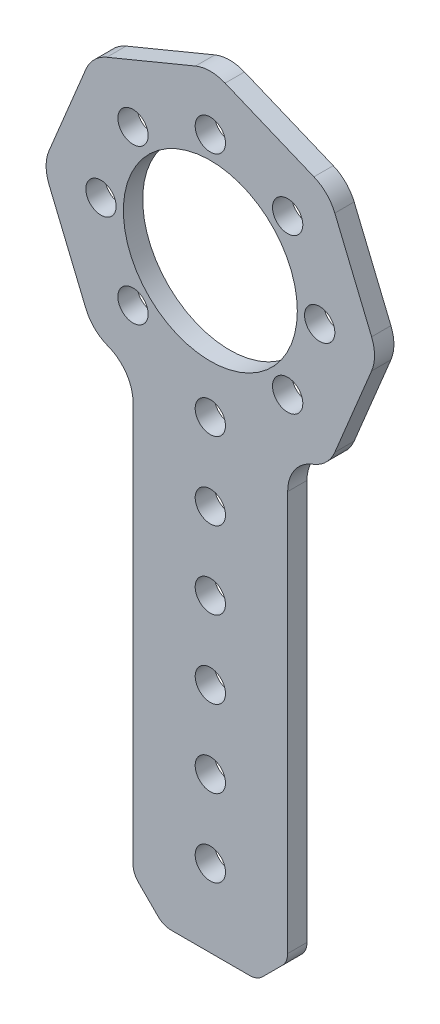
from build123d import *

# Parameters (mm, degrees)
SKETCH1_R           = 2.4892
SKETCH1_R_2         = 14.2875
BOSS_EXTRUDE1_DEPTH = 3.175


with BuildPart() as part:
    # Sketch1 → Boss-Extrude1 (new body)
    with BuildSketch(Plane(origin=(0, 0, -3.175), x_dir=(-1, 0, 0), z_dir=(0, 0, -1))):
        with BuildLine():
            Line((8.578679656, -97.553569989), (11.821320344, -94.310929302))
            ThreePointArc((11.821320344, -94.310929302), (12.471638598, -93.337659255), (12.7, -92.189608958))
            Line((12.7, -92.189608958), (12.7, -26.475183996))
            ThreePointArc((12.7, -26.475183996), (13.770167962, -22.947313016), (16.619960204, -20.608548965))
            Line((16.619960204, -20.608548965), (17.010278569, -20.446873805))
            ThreePointArc((17.010278569, -20.446873805), (19.070366834, -19.070366834), (20.446873805, -17.010278569))
            Line((20.446873805, -17.010278569), (26.486206447, -2.430039796))
            ThreePointArc((26.486206447, -2.430039796), (26.969571416, 0), (26.486206447, 2.430039796))
            Line((26.486206447, 2.430039796), (20.446873805, 17.010278569))
            ThreePointArc((20.446873805, 17.010278569), (19.070366834, 19.070366834), (17.010278569, 20.446873805))
            Line((17.010278569, 20.446873805), (2.430039796, 26.486206447))
            ThreePointArc((2.430039796, 26.486206447), (0, 26.969571416), (-2.430039796, 26.486206447))
            Line((-2.430039796, 26.486206447), (-17.010278569, 20.446873805))
            ThreePointArc((-17.010278569, 20.446873805), (-19.070366834, 19.070366834), (-20.446873805, 17.010278569))
            Line((-20.446873805, 17.010278569), (-26.486206447, 2.430039796))
            ThreePointArc((-26.486206447, 2.430039796), (-26.969571416, 0), (-26.486206447, -2.430039796))
            Line((-26.486206447, -2.430039796), (-20.446873805, -17.010278569))
            ThreePointArc((-20.446873805, -17.010278569), (-19.070366834, -19.070366834), (-17.010278569, -20.446873805))
            Line((-17.010278569, -20.446873805), (-16.619960204, -20.608548965))
            ThreePointArc((-16.619960204, -20.608548965), (-13.770167962, -22.947313016), (-12.7, -26.475183996))
            Line((-12.7, -26.475183996), (-12.7, -92.189608958))
            ThreePointArc((-12.7, -92.189608958), (-12.471638598, -93.337659255), (-11.821320344, -94.310929302))
            Line((-11.821320344, -94.310929302), (-8.578679656, -97.553569989))
            ThreePointArc((-8.578679656, -97.553569989), (-7.60540961, -98.203888243), (-6.457359313, -98.432249645))
            Line((-6.457359313, -98.432249645), (6.457359313, -98.432249645))
            ThreePointArc((6.457359313, -98.432249645), (7.60540961, -98.203888243), (8.578679656, -97.553569989))
        make_face()
        with Locations((12.7, -12.7)):
            Circle(SKETCH1_R, mode=Mode.SUBTRACT)
        Circle(SKETCH1_R_2, mode=Mode.SUBTRACT)
        with Locations((-12.7, 12.7)):
            Circle(SKETCH1_R, mode=Mode.SUBTRACT)
        with Locations((-17.960512242, 0)):
            Circle(SKETCH1_R, mode=Mode.SUBTRACT)
        with Locations((-12.7, -12.7)):
            Circle(SKETCH1_R, mode=Mode.SUBTRACT)
        with Locations((12.7, 12.7)):
            Circle(SKETCH1_R, mode=Mode.SUBTRACT)
        with Locations((17.960512242, 0)):
            Circle(SKETCH1_R, mode=Mode.SUBTRACT)
        with Locations((0, 17.960512242)):
            Circle(SKETCH1_R, mode=Mode.SUBTRACT)
        with Locations((0, -22.232249645)):
            Circle(SKETCH1_R, mode=Mode.SUBTRACT)
        with Locations((0, -73.032249645)):
            Circle(SKETCH1_R, mode=Mode.SUBTRACT)
        with Locations((0, -47.632249645)):
            Circle(SKETCH1_R, mode=Mode.SUBTRACT)
        with Locations((0, -34.932249645)):
            Circle(SKETCH1_R, mode=Mode.SUBTRACT)
        with Locations((0, -60.332249645)):
            Circle(SKETCH1_R, mode=Mode.SUBTRACT)
        with Locations((0, -85.732249645)):
            Circle(SKETCH1_R, mode=Mode.SUBTRACT)
    extrude(amount=-BOSS_EXTRUDE1_DEPTH)


solid = part.part
